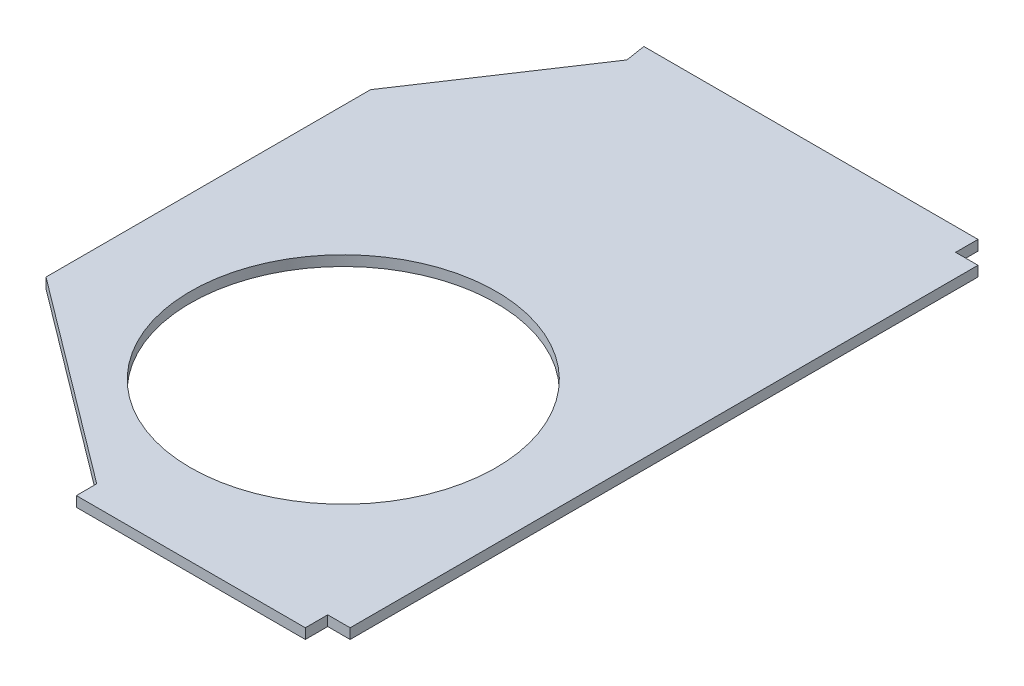
from build123d import *

# Parameters (mm, degrees)
BOSS_EXTRUDE2_DEPTH = 10
SKETCH4_W           = 20
SKETCH4_H           = 20
CUT_EXTRUDE1_DEPTH  = 10
SKETCH5_W           = 22
SKETCH5_H           = 22
CUT_EXTRUDE2_DEPTH  = 11
SKETCH6_R           = 150
CUT_EXTRUDE3_DEPTH  = 11


with BuildPart() as part:
    # Sketch1 → Boss-Extrude2 (new body)
    with BuildSketch(Plane(origin=(0, 0, 0), x_dir=(1, 0, 0), z_dir=(0, 1, 0))):
        Polygon((0, 0), (246.777636447, 0), (246.777636447, 660.361240582), (-103.222363553, 660.361240582), (-100.13363069, 640.601186703), (-200.677997122, 489.475620291), (-200.677997122, 330.180620291), (-200.677997122, 170.885620291), (0, 20), align=None)
    extrude(amount=BOSS_EXTRUDE2_DEPTH)

    # Sketch4 → Cut-Extrude1 (cut)
    with BuildSketch(Plane(origin=(0, 10, 0), x_dir=(1, 0, 0), z_dir=(0, 1, 0))):
        with Locations((-10, 348.38)):
            Rectangle(SKETCH4_W, SKETCH4_H)
    extrude(amount=-CUT_EXTRUDE1_DEPTH, mode=Mode.SUBTRACT)

    # Sketch5 → Cut-Extrude2 (cut, through all)
    with BuildSketch(Plane.XZ):
        with Locations((235.777636447, -649.361240582)):
            Rectangle(SKETCH5_W, SKETCH5_H)
        with Locations((235.777636447, -11)):
            Rectangle(SKETCH5_W, SKETCH5_H)
    extrude(amount=-CUT_EXTRUDE2_DEPTH, mode=Mode.SUBTRACT)

    # Sketch6 → Cut-Extrude3 (cut, through all)
    with BuildSketch(Plane(origin=(0, 10, 0), x_dir=(1, 0, 0), z_dir=(0, 1, 0))):
        with Locations((32.340951638, 229.684080555)):
            Circle(SKETCH6_R)
    extrude(amount=-CUT_EXTRUDE3_DEPTH, mode=Mode.SUBTRACT)


solid = part.part
